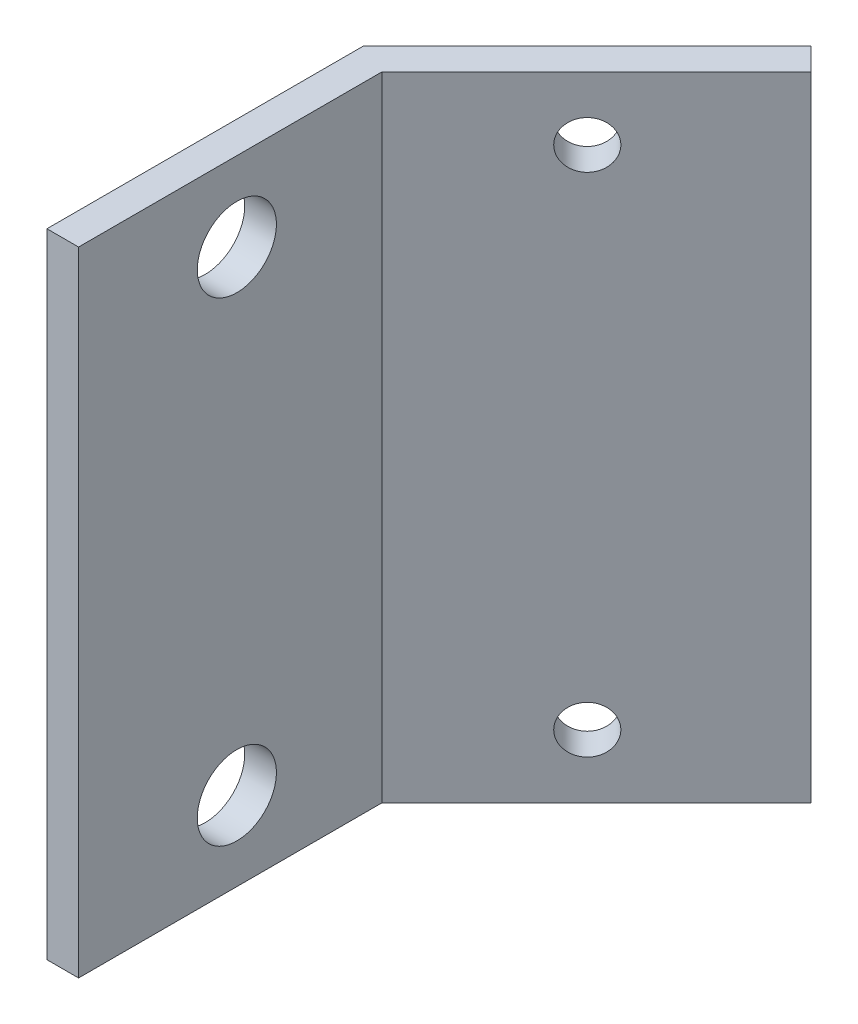
from build123d import *

# Parameters (mm, degrees)
EXTRUSION1_DEPTH = 40
EXTRUSION2_REACH = 17.556
ESQUISSE3_R      = 2.5
EXTRUSION3_REACH = 27.142
ESQUISSE4_R      = 1.5


with BuildPart() as part:
    # Esquisse1 → Extrusion1 (new body)
    with BuildSketch(Plane(origin=(0, 0, 0), x_dir=(1, 0, 0), z_dir=(0, 1, 0))):
        Polygon((0, 0), (0, 20), (14.142135624, 34.142135624), (15.556349186, 32.727922061), (2, 19.171572875), (2, 0), align=None)
    extrude(amount=EXTRUSION1_DEPTH)

    # Esquisse3 → Extrusion2 (cut, up to next)
    with BuildSketch(Plane.ZY, mode=Mode.PRIVATE) as extrusion2_sk1:
        with Locations((-10, 5)):
            Circle(ESQUISSE3_R)
    extrusion2_tool1 = extrude(extrusion2_sk1.sketch, amount=-EXTRUSION2_REACH, mode=Mode.PRIVATE) & part.part
    add(extrusion2_tool1.solids().sort_by_distance((0, 5, -10))[0], mode=Mode.SUBTRACT)
    # Esquisse3 → Extrusion2 (cut, up to next)
    with BuildSketch(Plane.ZY, mode=Mode.PRIVATE) as extrusion2_sk2:
        with Locations((-10, 35)):
            Circle(ESQUISSE3_R)
    extrusion2_tool2 = extrude(extrusion2_sk2.sketch, amount=-EXTRUSION2_REACH, mode=Mode.PRIVATE) & part.part
    add(extrusion2_tool2.solids().sort_by_distance((0, 35, -10))[0], mode=Mode.SUBTRACT)

    # Esquisse4 → Extrusion3 (cut, up to next)
    with BuildSketch(Plane(origin=(-10, 0, -10), x_dir=(-0.707106781, 0, 0.707106781), z_dir=(-0.707106781, 0, -0.707106781)), mode=Mode.PRIVATE) as extrusion3_sk1:
        with Locations((-24.142135624, 36)):
            Circle(ESQUISSE4_R)
    extrusion3_tool1 = extrude(extrusion3_sk1.sketch, amount=-EXTRUSION3_REACH, mode=Mode.PRIVATE) & part.part
    add(extrusion3_tool1.solids().sort_by_distance((7.071068, 36, -27.071068))[0], mode=Mode.SUBTRACT)
    # Esquisse4 → Extrusion3 (cut, up to next)
    with BuildSketch(Plane(origin=(-10, 0, -10), x_dir=(-0.707106781, 0, 0.707106781), z_dir=(-0.707106781, 0, -0.707106781)), mode=Mode.PRIVATE) as extrusion3_sk2:
        with Locations((-24.142135624, 4)):
            Circle(ESQUISSE4_R)
    extrusion3_tool2 = extrude(extrusion3_sk2.sketch, amount=-EXTRUSION3_REACH, mode=Mode.PRIVATE) & part.part
    add(extrusion3_tool2.solids().sort_by_distance((7.071068, 4, -27.071068))[0], mode=Mode.SUBTRACT)


solid = part.part
